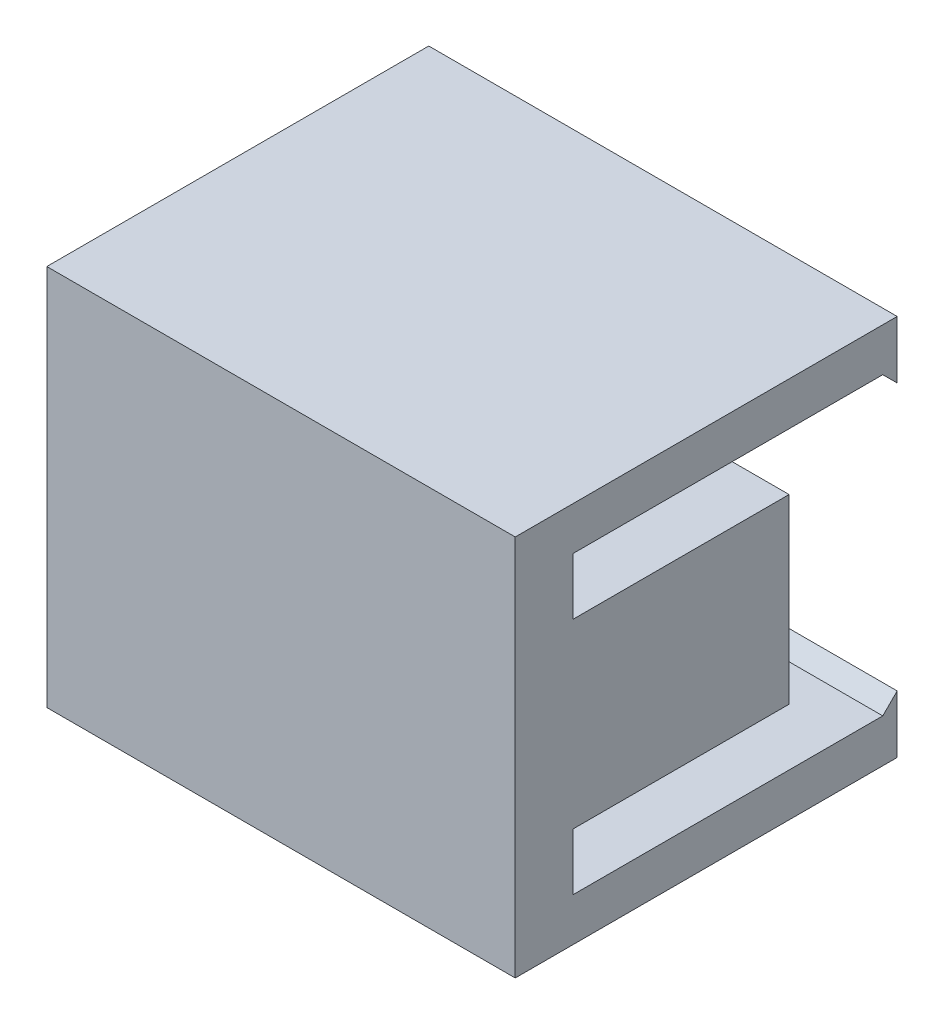
from build123d import *

# Parameters (mm, degrees)
SKETCH1_W           = 32.5
SKETCH1_H           = 26.5
BOSS_EXTRUDE1_DEPTH = 4
SKETCH2_W           = 6.5
SKETCH2_H           = 6.3
BOSS_EXTRUDE2_DEPTH = 15
SKETCH3_W           = 32.5
SKETCH3_H           = 3
BOSS_EXTRUDE3_DEPTH = 22.5
SKETCH4_W           = 32.5
SKETCH4_H           = 1
BOSS_EXTRUDE4_DEPTH = 1
CUT_EXTRUDE1_DEPTH  = 33.5
SKETCH6_W           = 32.5
SKETCH6_H           = 1
BOSS_EXTRUDE5_DEPTH = 1
CUT_EXTRUDE2_DEPTH  = 33.5
SKETCH8_W           = 3
SKETCH8_H           = 3.5
BOSS_EXTRUDE6_DEPTH = 15


with BuildPart() as part:
    # Sketch1 → Boss-Extrude1 (new body)
    with BuildSketch(Plane.XY):
        Rectangle(SKETCH1_W, SKETCH1_H)
    extrude(amount=BOSS_EXTRUDE1_DEPTH)

    # Sketch2 → Boss-Extrude2 (add)
    with BuildSketch(Plane(origin=(0, 0, 0), x_dir=(-1, 0, 0), z_dir=(0, 0, -1))):
        with Locations((-13, -3.15)):
            Rectangle(SKETCH2_W, SKETCH2_H)
        with Locations((-13, 3.15)):
            Rectangle(SKETCH2_W, SKETCH2_H)
    extrude(amount=BOSS_EXTRUDE2_DEPTH)

    # Sketch3 → Boss-Extrude3 (add)
    with BuildSketch(Plane(origin=(0, 0, 0), x_dir=(-1, 0, 0), z_dir=(0, 0, -1))):
        with Locations((0, -11.75)):
            Rectangle(SKETCH3_W, SKETCH3_H)
        with Locations((0, 11.75)):
            Rectangle(SKETCH3_W, SKETCH3_H)
    extrude(amount=BOSS_EXTRUDE3_DEPTH)

    # Sketch4 → Boss-Extrude4 (add)
    with BuildSketch(Plane(origin=(0, -10.25, 0), x_dir=(1, 0, 0), z_dir=(0, 1, 0))):
        with Locations((0, 22)):
            Rectangle(SKETCH4_W, SKETCH4_H)
    extrude(amount=BOSS_EXTRUDE4_DEPTH)

    # Sketch5 → Cut-Extrude1 (cut, through all)
    with BuildSketch(Plane.ZY.offset(16.25)):
        Polygon((-21.5, -10.25), (-22.5, -9.25), (-21.5, -9.25), align=None)
    extrude(amount=-CUT_EXTRUDE1_DEPTH, mode=Mode.SUBTRACT)

    # Sketch6 → Boss-Extrude5 (add)
    with BuildSketch(Plane.XZ.offset(-10.25)):
        with Locations((0, -22)):
            Rectangle(SKETCH6_W, SKETCH6_H)
    extrude(amount=BOSS_EXTRUDE5_DEPTH)

    # Sketch7 → Cut-Extrude2 (cut, through all)
    with BuildSketch(Plane.ZY.offset(16.25)):
        Polygon((-21.5, 10.25), (-21.5, 9.25), (-22.5, 9.25), align=None)
    extrude(amount=-CUT_EXTRUDE2_DEPTH, mode=Mode.SUBTRACT)

    # Sketch8 → Boss-Extrude6 (add)
    with BuildSketch(Plane(origin=(0, 0, 0), x_dir=(-1, 0, 0), z_dir=(0, 0, -1))):
        with Locations((14.75, 3.75)):
            Rectangle(SKETCH8_W, SKETCH8_H)
        with Locations((14.75, -3.76990678)):
            Rectangle(SKETCH8_W, SKETCH8_H)
    extrude(amount=BOSS_EXTRUDE6_DEPTH)


solid = part.part
